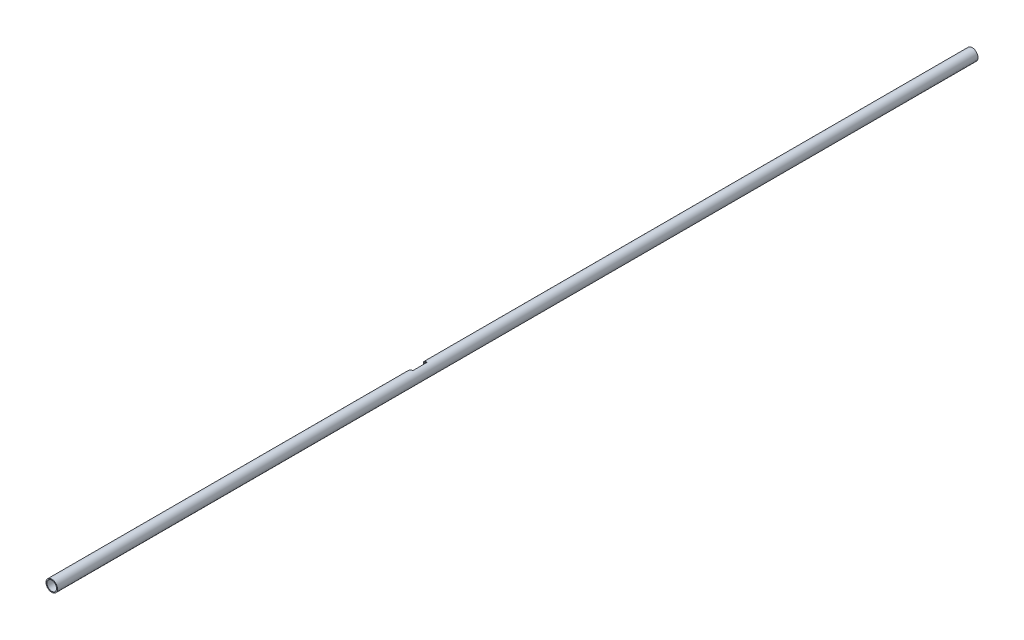
from build123d import *

# Parameters (mm, degrees)
SKETCH1_R           = 19.05
SKETCH1_R_2         = 15.875
BOSS_EXTRUDE1_DEPTH = 3048
SKETCH2_R           = 30.226
CUT_EXTRUDE1_DEPTH  = 20.05


with BuildPart() as part:
    # Sketch1 → Boss-Extrude1 (new body)
    with BuildSketch(Plane.XY):
        Circle(SKETCH1_R)
        Circle(SKETCH1_R_2, mode=Mode.SUBTRACT)
    extrude(amount=BOSS_EXTRUDE1_DEPTH)

    # Sketch2 → Cut-Extrude1 (cut, through all)
    with BuildSketch(Plane(origin=(0, 0, 0), x_dir=(0, 0, -1), z_dir=(1, 0, 0))):
        with Locations((-1828.8, 0)):
            Circle(SKETCH2_R)
    extrude(amount=-CUT_EXTRUDE1_DEPTH, mode=Mode.SUBTRACT)


solid = part.part
